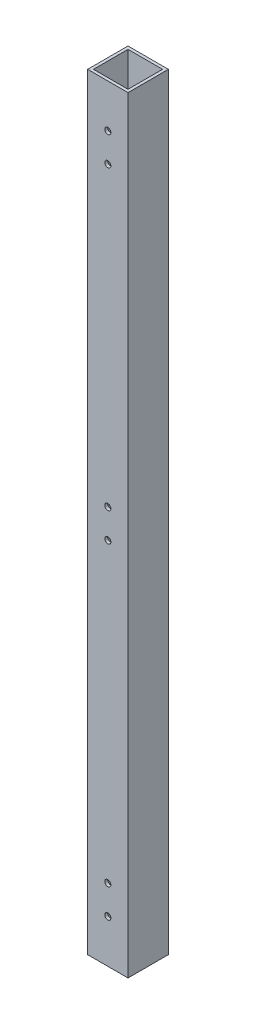
from build123d import *

# Parameters (mm, degrees)
SKETCH1_W                        = 44.45
SKETCH1_H                        = 44.45
SKETCH1_W_2                      = 38.1
SKETCH1_H_2                      = 38.1
BOSS_EXTRUDE1_DEPTH              = 844.55
F_17_64_0_26563_DIAMETER_HOLE1_D = 6.747002


with BuildPart() as part:
    # Sketch1 → Boss-Extrude1 (new body)
    with BuildSketch(Plane(origin=(0, 0, 0), x_dir=(1, 0, 0), z_dir=(0, 1, 0))):
        with Locations((22.225, 22.225)):
            Rectangle(SKETCH1_W, SKETCH1_H)
        with Locations((22.225, 22.225)):
            Rectangle(SKETCH1_W_2, SKETCH1_H_2, mode=Mode.SUBTRACT)
    extrude(amount=BOSS_EXTRUDE1_DEPTH)

    # 17/64 (0.26563) Diameter Hole1 (through all)
    with Locations(Plane.XY):
        with Locations((22.225, 796.925), (22.225, 765.175), (22.225, 438.15), (22.225, 406.4), (22.225, 79.375), (22.225, 47.625)):
            Hole(F_17_64_0_26563_DIAMETER_HOLE1_D / 2)


solid = part.part
